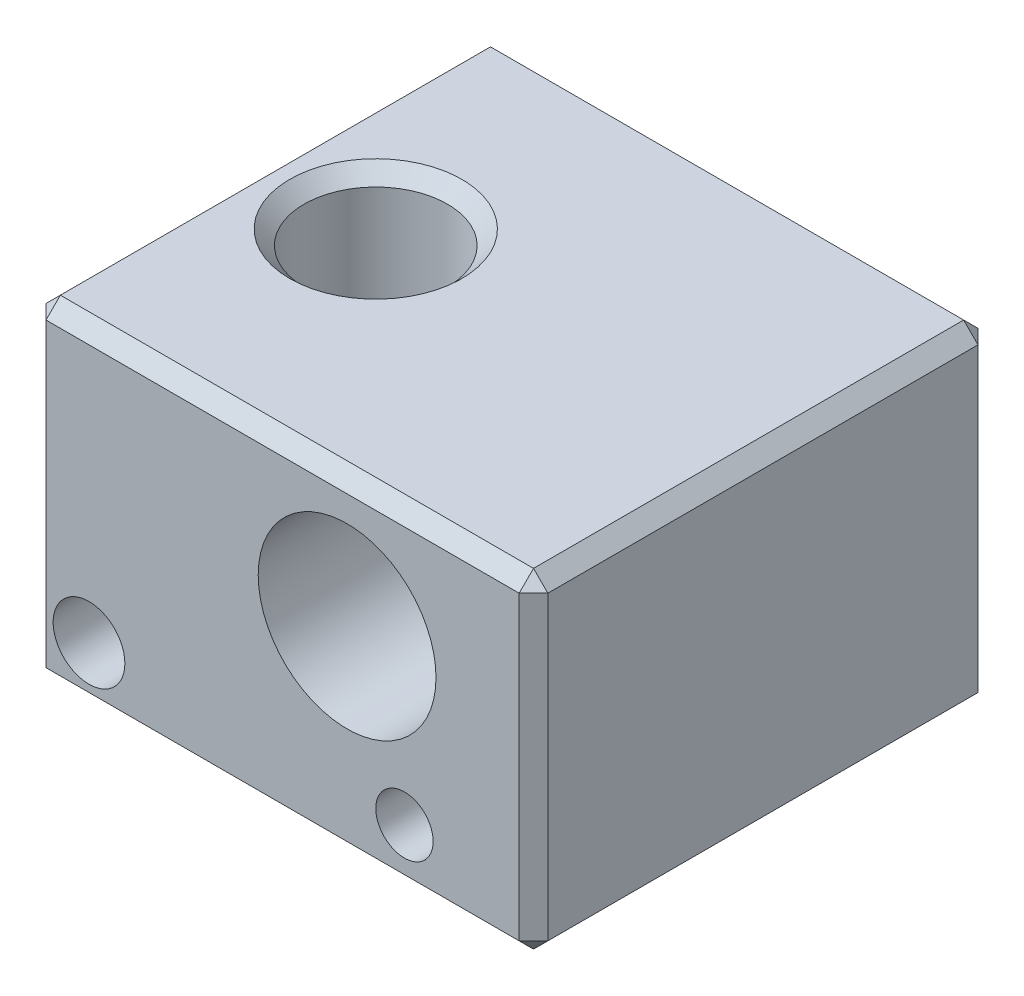
from build123d import *

# Parameters (mm, degrees)
SKETCH1_W                       = 17.5
SKETCH1_H                       = 16
BOSS_EXTRUDE1_DEPTH             = 11.5
SKETCH2_R                       = 3.1
SKETCH2_R_2                     = 1
CUT_EXTRUDE1_DEPTH              = 17
F_2_5_2_5_DIAMETER_HOLE1_D      = 2.5
F_2_5_2_5_DIAMETER_HOLE1_DEPTH  = 4.5
TAP_DRILL_FOR_M6X1_0_TAP1_D     = 5
TAP_DRILL_FOR_M3X0_5_TAP1_D     = 2.5
TAP_DRILL_FOR_M3X0_5_TAP1_DEPTH = 6.999
TAP_DRILL_FOR_M3X0_5_TAP1_TIP   = 0.751075774
CHAMFER1_SIZE                   = 0.5


with BuildPart() as part:
    # Sketch1 → Boss-Extrude1 (new body)
    with BuildSketch(Plane(origin=(0, 0, 0), x_dir=(1, 0, 0), z_dir=(0, 1, 0))):
        Rectangle(SKETCH1_W, SKETCH1_H)
    extrude(amount=BOSS_EXTRUDE1_DEPTH)

    # Sketch2 → Cut-Extrude1 (cut, through all)
    with BuildSketch(Plane.XY.offset(8)):
        with Locations((2.25, 7)):
            Circle(SKETCH2_R)
        with Locations((4.25, 2)):
            Circle(SKETCH2_R_2)
    extrude(amount=-CUT_EXTRUDE1_DEPTH, mode=Mode.SUBTRACT)

    # Ø2.5 (2.5) Diameter Hole1
    with Locations(Plane.XY.offset(8)):
        with Locations((-6.75, 2)):
            Hole(F_2_5_2_5_DIAMETER_HOLE1_D / 2, depth=F_2_5_2_5_DIAMETER_HOLE1_DEPTH)

    # Tap Drill for M6x1.0 Tap1 (through all)
    with Locations(Plane(origin=(0, 11.5, 0), x_dir=(1, 0, 0), z_dir=(0, 1, 0))):
        with Locations((-4.75, 0)):
            Hole(TAP_DRILL_FOR_M6X1_0_TAP1_D / 2)

    # Tap Drill for M3x0.5 Tap1
    with Locations(Plane(origin=(0, 0, 0), x_dir=(-1, 0, 0), z_dir=(0, -1, 0))):
        with Locations((-1.25, 0)):
            Hole(TAP_DRILL_FOR_M3X0_5_TAP1_D / 2, depth=TAP_DRILL_FOR_M3X0_5_TAP1_DEPTH)
            with Locations((0, 0, -(TAP_DRILL_FOR_M3X0_5_TAP1_DEPTH + TAP_DRILL_FOR_M3X0_5_TAP1_TIP / 2))):  # 118° drill point
                Cone(0, TAP_DRILL_FOR_M3X0_5_TAP1_D / 2, TAP_DRILL_FOR_M3X0_5_TAP1_TIP, mode=Mode.SUBTRACT)

    # Chamfer1
    chamfer1_edges = [part.edges().sort_by_distance(p)[0] for p in [
        (0, 11.5, -8),
        (-8.75, 11.5, 0),
        (-2.25, 11.5, 0),
        (-2.25, 0, 0),
        (0, 0, 0),
        (0, 11.5, 8),
        (-8.75, 0, 0),
        (0, 0, -8),
        (8.75, 0, 0),
        (0, 0, 8),
        (8.75, 11.5, 0),
        (-8.75, 5.75, 8),
        (-8.75, 5.75, -8),
        (8.75, 5.75, -8),
        (8.75, 5.75, 8),
    ]]
    chamfer(chamfer1_edges, length=CHAMFER1_SIZE)


solid = part.part
